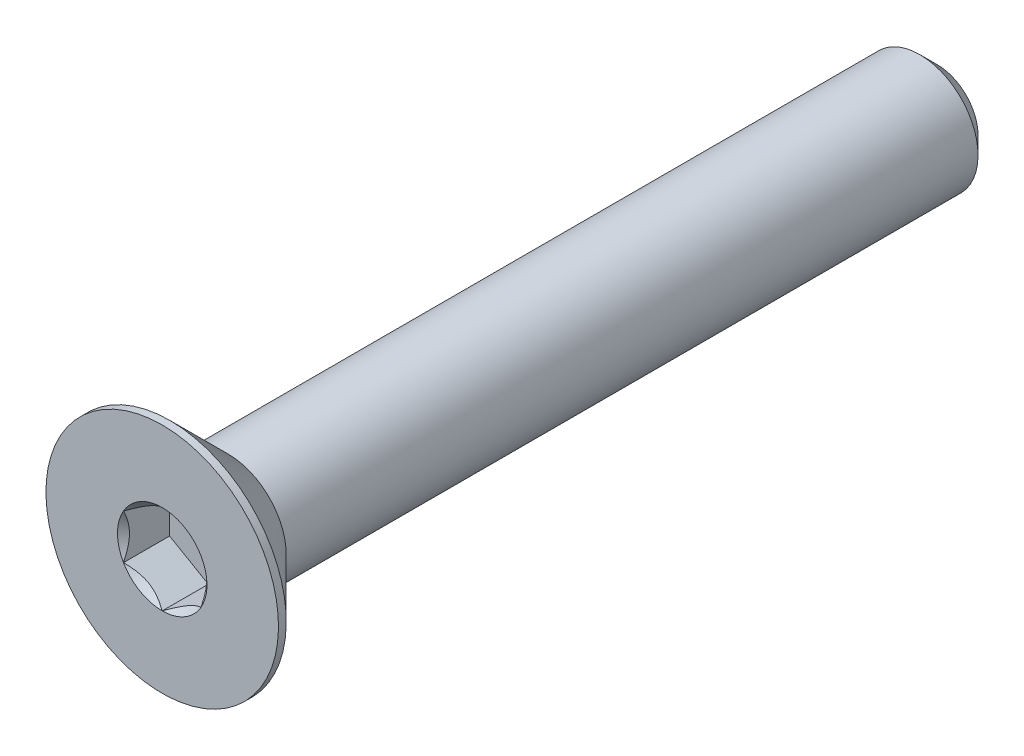
from build123d import *

# Parameters (mm, degrees)
SKETCH3_W          = 20
SKETCH3_H          = 1.5
CHAMFER1_SIZE      = 0.45
CUT_EXTRUDE1_DEPTH = 1.19


with BuildPart() as part:
    # Sketch3 → Revolve1 (revolve)
    with BuildSketch(Plane(origin=(0, 0, 0), x_dir=(0, 0, -1), z_dir=(1, 0, 0))):
        with Locations((0, 0.75)):
            Rectangle(SKETCH3_W, SKETCH3_H)
    revolve(axis=Axis((0, 0, -10), (0, 0, 1)))

    # Chamfer1
    chamfer1_edges = [part.edges().sort_by_distance(p)[0] for p in [
        (0, -1.5, -10),
    ]]
    chamfer(chamfer1_edges, length=CHAMFER1_SIZE)

    # Sketch6 → Revolve2 (revolve)
    with BuildSketch(Plane(origin=(0, 0, 0), x_dir=(0, 0, -1), z_dir=(1, 0, 0))):
        Polygon((-10, 3), (-9.8, 3), (-8.3, 1.5), (-8.3, 0), (-10, 0), align=None)
    revolve(axis=Axis((0, 0, -10), (0, 0, 1)))

    # Sketch8 → Cut-Extrude1 (cut)
    with BuildSketch(Plane.XY.offset(10)):
        Polygon((0, 1.154700538), (-1, 0.577350269), (-1, -0.577350269), (0, -1.154700538), (1, -0.577350269), (1, 0.577350269), align=None)
    extrude(amount=-CUT_EXTRUDE1_DEPTH, mode=Mode.SUBTRACT)

    # Cut-Extrude2 cone 1 section (through the dimple's axis) → Cut-Extrude2 (revolve, cut)
    with BuildSketch(Plane(origin=(0, 0, 10), x_dir=(0, -1, 0), z_dir=(1, 0, 0))):
        Polygon((0, 0), (1.154700538, 0), (0, 1.154700538), align=None)
    revolve(axis=Axis((0, 0, 10), (0, 0, -1)), mode=Mode.SUBTRACT)


solid = part.part
